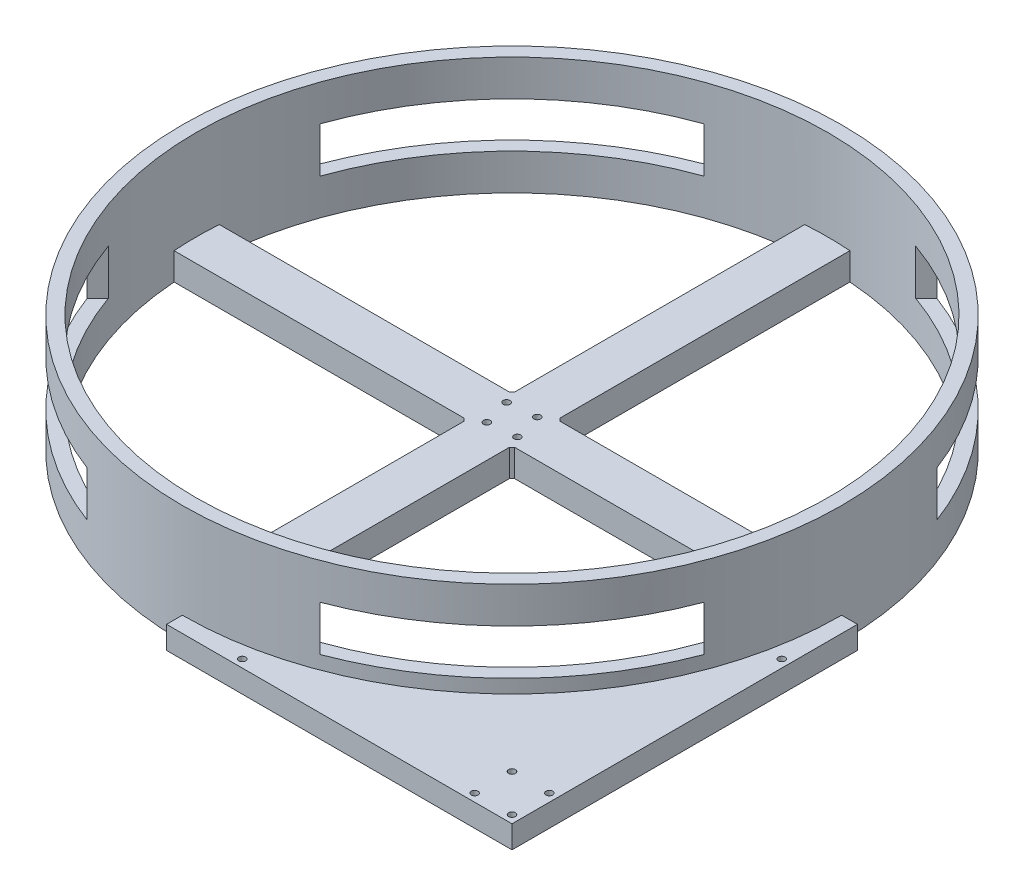
from build123d import *

# Parameters (mm, degrees)
SKETCH1_R           = 145.7
SKETCH1_R_2         = 139.7
BOSS_EXTRUDE1_DEPTH = 60
SKETCH2_R           = 15
BOSS_EXTRUDE2_DEPTH = 12
BOSS_EXTRUDE3_DEPTH = 10
SKETCH4_R           = 1.5
CUT_EXTRUDE1_DEPTH  = 62
SKETCH1_2_R         = 145.7
SKETCH1_2_R_2       = 139.7
CUT_EXTRUDE2_DEPTH  = 8
SKETCH5_W           = 20
SKETCH5_H           = 120
CUT_EXTRUDE3_DEPTH  = 55
CIRPATTERN1_COUNT   = 4
SKETCH6_R           = 1.5
CUT_EXTRUDE4_DEPTH  = 37


with BuildPart() as part:
    # Sketch1 → Boss-Extrude1 (new body)
    with BuildSketch(Plane(origin=(0, 0, 0), x_dir=(1, 0, 0), z_dir=(0, 1, 0))):
        with Locations((-152.664354058, 152.664354058)):
            Circle(SKETCH1_R)
        with Locations((-152.664354058, 152.664354058)):
            Circle(SKETCH1_R_2, mode=Mode.SUBTRACT)
    extrude(amount=BOSS_EXTRUDE1_DEPTH)

    # Sketch2 → Boss-Extrude2 (add)
    with BuildSketch(Plane(origin=(0, 8, 0), x_dir=(-1, 0, 0), z_dir=(0, -1, 0))):
        with BuildLine():
            ThreePointArc((13.322723524, 162.664354058), (12.964354058, 152.664354058), (13.322723524, 142.664354058))
            Line((13.322723524, 142.664354058), (137.664354058, 142.664354058))
            Line((137.664354058, 142.664354058), (141.484014171, 142.664354058))
            ThreePointArc((141.484014171, 142.664354058), (137.664354058, 152.664354058), (141.484014171, 162.664354058))
            Line((141.484014171, 162.664354058), (137.664354058, 162.664354058))
            Line((137.664354058, 162.664354058), (13.322723524, 162.664354058))
        make_face()
        with BuildLine():
            ThreePointArc((162.664354058, 292.005984593), (152.664354058, 292.364354058), (142.664354058, 292.005984593))
            Line((142.664354058, 292.005984593), (142.664354058, 167.664354058))
            Line((142.664354058, 167.664354058), (142.664354058, 163.844693946))
            ThreePointArc((142.664354058, 163.844693946), (152.664354058, 167.664354058), (162.664354058, 163.844693946))
            Line((162.664354058, 163.844693946), (162.664354058, 167.664354058))
            Line((162.664354058, 167.664354058), (162.664354058, 292.005984593))
        make_face()
        with BuildLine():
            Line((167.664354058, 142.664354058), (292.005984593, 142.664354058))
            ThreePointArc((292.005984593, 142.664354058), (292.274732945, 147.661144372), (292.364354058, 152.664354058))
            ThreePointArc((292.364354058, 152.664354058), (292.274732945, 157.667563745), (292.005984593, 162.664354058))
            Line((292.005984593, 162.664354058), (167.664354058, 162.664354058))
            Line((167.664354058, 162.664354058), (163.844693946, 162.664354058))
            ThreePointArc((163.844693946, 162.664354058), (166.676939443, 158.016685405), (167.664354058, 152.664354058))
            ThreePointArc((167.664354058, 152.664354058), (166.676939443, 147.312022712), (163.844693946, 142.664354058))
            Line((163.844693946, 142.664354058), (167.664354058, 142.664354058))
        make_face()
        with BuildLine():
            Line((142.664354058, 141.484014171), (142.664354058, 137.664354058))
            Line((142.664354058, 137.664354058), (142.664354058, 13.322723524))
            ThreePointArc((142.664354058, 13.322723524), (152.664354058, 12.964354058), (162.664354058, 13.322723524))
            Line((162.664354058, 13.322723524), (162.664354058, 137.664354058))
            Line((162.664354058, 137.664354058), (162.664354058, 141.484014171))
            ThreePointArc((162.664354058, 141.484014171), (152.664354058, 137.664354058), (142.664354058, 141.484014171))
        make_face()
        with Locations((152.664354058, 152.664354058)):
            Circle(SKETCH2_R)
    extrude(amount=-BOSS_EXTRUDE2_DEPTH)

    # Sketch3 → Boss-Extrude3 (add)
    with BuildSketch(Plane(origin=(0, 8, 0), x_dir=(-1, 0, 0), z_dir=(0, -1, 0))):
        with BuildLine():
            Line((152.664354058, 6.964354058), (152.664354058, 0))
            Line((152.664354058, 0), (0, 0))
            Line((0, 0), (0, 152.664354058))
            Line((0, 152.664354058), (6.964354058, 152.664354058))
            ThreePointArc((6.964354058, 152.664354058), (49.638896039, 49.638896039), (152.664354058, 6.964354058))
        make_face()
    extrude(amount=-BOSS_EXTRUDE3_DEPTH)

    # Sketch4 → Cut-Extrude1 (cut)
    with BuildSketch(Plane(origin=(0, 18, 0), x_dir=(1, 0, 0), z_dir=(0, 1, 0))):
        with Locations((-122.664354058, 3.482177029)):
            Circle(SKETCH4_R)
        with Locations((-20, 3.482177029)):
            Circle(SKETCH4_R)
        with Locations((-20, 20.002177029)):
            Circle(SKETCH4_R)
        with Locations((-3.482177029, 20.002177029)):
            Circle(SKETCH4_R)
        with Locations((-3.482177029, 3.482177029)):
            Circle(SKETCH4_R)
        with Locations((-3.482177029, 122.664354058)):
            Circle(SKETCH4_R)
    extrude(amount=-CUT_EXTRUDE1_DEPTH, mode=Mode.SUBTRACT)

    # Sketch1_2 → Cut-Extrude2 (cut)
    with BuildSketch(Plane(origin=(0, 0, 0), x_dir=(1, 0, 0), z_dir=(0, 1, 0))):
        with Locations((-152.664354058, 152.664354058)):
            Circle(SKETCH1_2_R)
        with Locations((-152.664354058, 152.664354058)):
            Circle(SKETCH1_2_R_2, mode=Mode.SUBTRACT)
    extrude(amount=CUT_EXTRUDE2_DEPTH, mode=Mode.SUBTRACT)

    # Sketch5 → Cut-Extrude3 (cut)
    with BuildSketch(Plane(origin=(-255.689812077, 0, -255.689812077), x_dir=(0, -1, 0), z_dir=(-0.707106781, 0, -0.707106781))):
        with Locations((-34, 0)):
            Rectangle(SKETCH5_W, SKETCH5_H)
    cut_extrude3 = extrude(amount=-CUT_EXTRUDE3_DEPTH, mode=Mode.SUBTRACT)

    # CirPattern1: Cut-Extrude3 ×4 about axis
    cirpattern1_axis = Axis((-152.664354058, 0, -152.664354058), (0, 1, 0))
    for i in range(1, CIRPATTERN1_COUNT):
        add(cut_extrude3.rotate(cirpattern1_axis, i * 360 / CIRPATTERN1_COUNT), mode=Mode.SUBTRACT)

    # Sketch6 → Cut-Extrude4 (cut)
    with BuildSketch(Plane(origin=(0, 20, 0), x_dir=(1, 0, 0), z_dir=(0, 1, 0))):
        with BuildLine():
            ThreePointArc((-144.104525473, 148.543755244), (-146.092112388, 148.103034136), (-145.809681622, 146.086857134))
            ThreePointArc((-145.809681622, 146.086857134), (-143.627521762, 146.392539165), (-144.104525473, 148.543755244))
        make_face()
        with Locations((-157.22567398, 146.092112388)):
            Circle(SKETCH6_R)
        with Locations((-148.103034136, 159.236595728)):
            Circle(SKETCH6_R)
        with BuildLine():
            ThreePointArc((-159.519026494, 159.241850983), (-161.701186354, 158.936168951), (-161.224182644, 156.784952872))
            ThreePointArc((-161.224182644, 156.784952872), (-159.236595728, 157.22567398), (-159.519026494, 159.241850983))
        make_face()
    extrude(amount=-CUT_EXTRUDE4_DEPTH, mode=Mode.SUBTRACT)


solid = part.part
